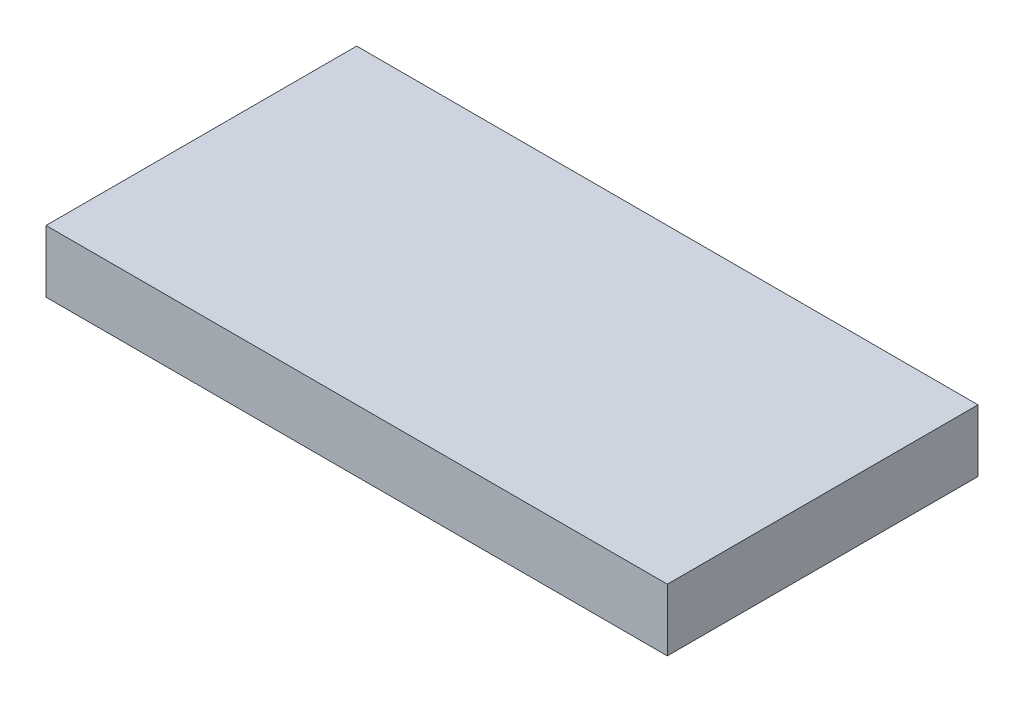
from build123d import *

# Parameters (mm, degrees)
SKETCH_1_W      = 100
SKETCH_1_H      = 50
EXTRUDE_1_DEPTH = 10


with BuildPart() as part:
    # 草图1 → 凸台-拉伸1 (new body)
    with BuildSketch(Plane(origin=(0, 0, 0), x_dir=(1, 0, 0), z_dir=(0, 1, 0))):
        Rectangle(SKETCH_1_W, SKETCH_1_H)
    extrude(amount=EXTRUDE_1_DEPTH)


solid = part.part
